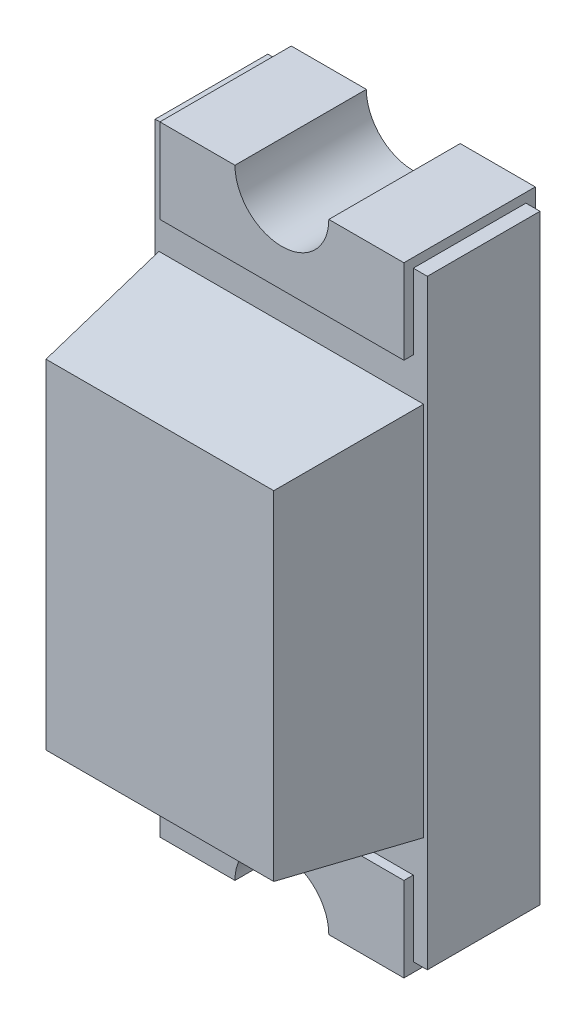
from build123d import *

# Parameters (mm, degrees)
RESSALTO_EXTRUS_O1_DEPTH   = 0.35
RESSALTO_EXTRUS_O1_2_DEPTH = 0.35
RESSALTO_EXTRUS_O2_START   = 0.025
RESSALTO_EXTRUS_O2_DEPTH   = 0.3
ESBO_O3_W                  = 0.705
ESBO_O3_H                  = 1
RESSALTO_EXTRUS_O3_DEPTH   = 0.35
RESSALTO_EXTRUS_O3_TAPER   = 8


with BuildPart() as part:
    # Esboço1 → Ressalto-extrusão1 (new body)
    with BuildSketch(Plane.XY):
        with BuildLine():
            Line((0.873613743, 0.20755841), (1.073613743, 0.20755841))
            ThreePointArc((1.073613743, 0.20755841), (1.198613743, 0.08255841), (1.323613743, 0.20755841))
            Line((1.323613743, 0.20755841), (1.523613743, 0.20755841))
            Line((1.523613743, 0.20755841), (1.523613743, -0.01744159))
            Line((1.523613743, -0.01744159), (0.873613743, -0.01744159))
            Line((0.873613743, -0.01744159), (0.873613743, 0.20755841))
        make_face()
    extrude(amount=RESSALTO_EXTRUS_O1_DEPTH)



with BuildPart() as body_2:
    # Esboço1 → Ressalto-extrus_o1 2 (new body)
    with BuildSketch(Plane.XY):
        with BuildLine():
            Line((0.873613743, -1.21744159), (1.523613743, -1.21744159))
            Line((1.523613743, -1.21744159), (1.523613743, -1.44244159))
            Line((1.523613743, -1.44244159), (1.323613743, -1.44244159))
            ThreePointArc((1.323613743, -1.44244159), (1.198613743, -1.31744159), (1.073613743, -1.44244159))
            Line((1.073613743, -1.44244159), (0.873613743, -1.44244159))
            Line((0.873613743, -1.44244159), (0.873613743, -1.21744159))
        make_face()
    extrude(amount=RESSALTO_EXTRUS_O1_2_DEPTH)


with BuildPart() as part_1:
    add(part.part)

    add(body_2.part)  # Ressalto-extrusão2 merges body 2
    # Esboço2 → Ressalto-extrusão2 (add)
    with BuildSketch(Plane.XY.offset(RESSALTO_EXTRUS_O2_START)):
        with BuildLine():
            Line((0.836113743, 0.18255841), (1.023613743, 0.18255841))
            ThreePointArc((1.023613743, 0.18255841), (1.198613743, 0.00755841), (1.373613743, 0.18255841))
            Line((1.373613743, 0.18255841), (1.561113743, 0.18255841))
            Line((1.561113743, 0.18255841), (1.561113743, -1.41744159))
            Line((1.561113743, -1.41744159), (1.373613743, -1.41744159))
            ThreePointArc((1.373613743, -1.41744159), (1.198613743, -1.24244159), (1.023613743, -1.41744159))
            Line((1.023613743, -1.41744159), (0.836113743, -1.41744159))
            Line((0.836113743, -1.41744159), (0.836113743, 0.18255841))
        make_face()
    extrude(amount=RESSALTO_EXTRUS_O2_DEPTH)

    # Esboço3 → Ressalto-extrusão3 (add)
    with BuildSketch(Plane.XY.offset(0.325)):
        with Locations((1.198613743, -0.61744159)):
            Rectangle(ESBO_O3_W, ESBO_O3_H)
    extrude(amount=RESSALTO_EXTRUS_O3_DEPTH, taper=RESSALTO_EXTRUS_O3_TAPER)


solid = part_1.part
